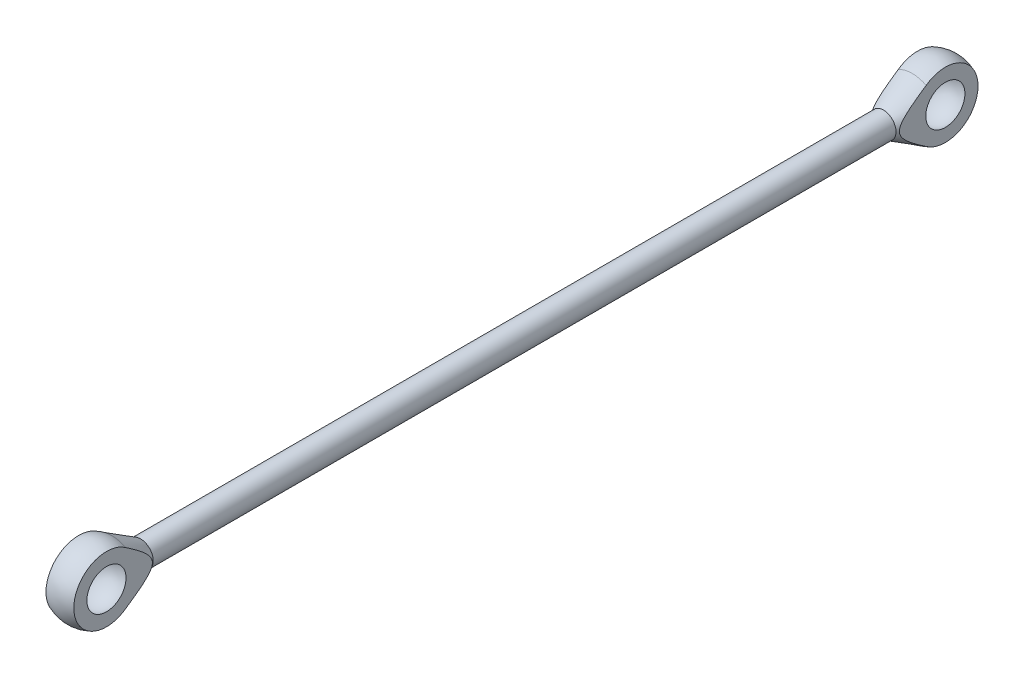
from build123d import *

# Parameters (mm, degrees)
SKETCH3_R           = 5
BOSS_EXTRUDE2_DEPTH = 332
CUT_EXTRUDE1_START  = -5.5
SKETCH7_R           = 24.093580554
CUT_EXTRUDE1_DEPTH  = 342.119975622
CUT_EXTRUDE2_START  = 5.5
SKETCH7_2_R         = 24.093580554
CUT_EXTRUDE2_DEPTH  = 342.119975622


with BuildPart() as part:
    # Sketch3 → Boss-Extrude2 (new body)
    with BuildSketch(Plane.XY):
        Circle(SKETCH3_R)
    extrude(amount=BOSS_EXTRUDE2_DEPTH)

    # Sketch4 → Revolve10 (revolve)
    with BuildSketch(Plane(origin=(0, 0, 0), x_dir=(1, 0, 0), z_dir=(0, 1, 0))):
        with BuildLine():
            Line((14.05, -332), (-14.05, -332))
            ThreePointArc((-14.05, -332), (0, -346.05), (14.05, -332))
        make_face()
    revolve(axis=Axis((-14.05, 0, 332), (1, 0, 0)))

    # Sketch4_6 → Revolve11 (revolve)
    with BuildSketch(Plane(origin=(0, 0, 0), x_dir=(1, 0, 0), z_dir=(0, 1, 0))):
        with BuildLine():
            ThreePointArc((14.05, 0), (0, 14.05), (-14.05, 0))
            Line((-14.05, 0), (14.05, 0))
        make_face()
    revolve(axis=Axis((-14.05, 0, 0), (1, 0, 0)))

    # Sketch8 → Revolve12 (revolve)
    with BuildSketch(Plane(origin=(0, 0, 0), x_dir=(1, 0, 0), z_dir=(0, 1, 0))):
        Polygon((12.29, -6.808700317), (0, -6.808700317), (0, -19.01), (5, -19.01), align=None)
    revolve(axis=Axis((0, 0, 19.01), (0, 0, -1)))

    # Sketch8_3 → Revolve13 (revolve)
    with BuildSketch(Plane(origin=(0, 0, 0), x_dir=(1, 0, 0), z_dir=(0, 1, 0))):
        Polygon((5, -312.99), (0, -312.99), (0, -325.191299683), (12.29, -325.191299683), align=None)
    revolve(axis=Axis((0, 0, 312.99), (0, 0, 1)))

    # Sketch7 → Cut-Extrude1 (cut, through all)
    with BuildSketch(Plane(origin=(0, 0, 0), x_dir=(0, 0, -1), z_dir=(1, 0, 0)).offset(CUT_EXTRUDE1_START)):
        Circle(SKETCH7_R)
        with Locations((-332, 0)):
            Circle(SKETCH7_R)
    extrude(amount=-CUT_EXTRUDE1_DEPTH, mode=Mode.SUBTRACT)

    # Sketch7_2 → Cut-Extrude2 (cut, through all)
    with BuildSketch(Plane(origin=(0, 0, 0), x_dir=(0, 0, -1), z_dir=(1, 0, 0)).offset(CUT_EXTRUDE2_START)):
        Circle(SKETCH7_2_R)
        with Locations((-332, 0)):
            Circle(SKETCH7_2_R)
    extrude(amount=CUT_EXTRUDE2_DEPTH, mode=Mode.SUBTRACT)

    # Sketch6 → Cut-Revolve1 (revolve, cut)
    with BuildSketch(Plane(origin=(0, 0, 0), x_dir=(1, 0, 0), z_dir=(0, 1, 0))):
        with BuildLine():
            ThreePointArc((9.5, 0), (0, 9.5), (-9.5, 0))
            Line((-9.5, 0), (9.5, 0))
        make_face()
    revolve(axis=Axis((-9.5, 0, 0), (1, 0, 0)), mode=Mode.SUBTRACT)

    # Sketch6_3 → Cut-Revolve2 (revolve, cut)
    with BuildSketch(Plane(origin=(0, 0, 0), x_dir=(1, 0, 0), z_dir=(0, 1, 0))):
        with BuildLine():
            Line((-9.5, -332), (9.5, -332))
            ThreePointArc((9.5, -332), (0, -341.5), (-9.5, -332))
        make_face()
    revolve(axis=Axis((-9.5, 0, 332), (1, 0, 0)), mode=Mode.SUBTRACT)


solid = part.part
